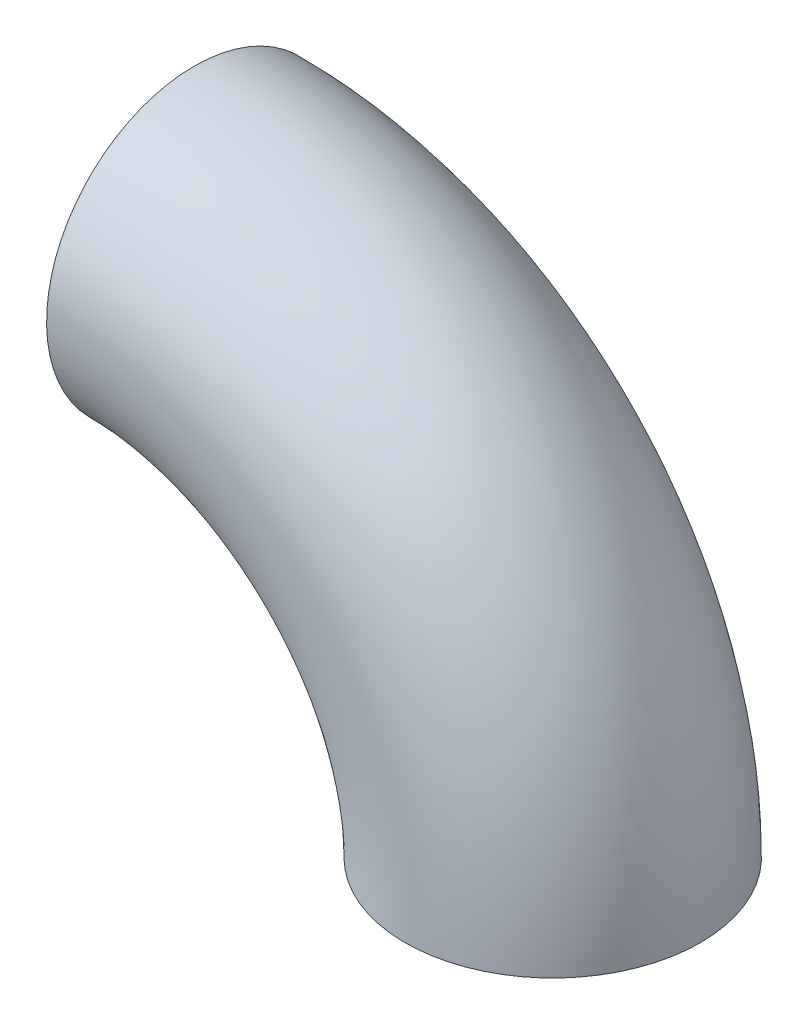
from build123d import *

# Parameters (mm, degrees)
SKETCH1_R   = 22.225
SKETCH1_R_2 = 20.574


with BuildPart() as part:
    # Sweep1: sweep along a curve in space
    with BuildLine() as sweep1_path:
        ThreePointArc((22.225, 0, 0), (-0.093463274, 53.881536726, 0), (-53.975, 76.2, 0))
    # Sketch1 → Sweep1 (sweep)
    with BuildSketch(Plane(origin=(0, 0, 0), x_dir=(1, 0, 0), z_dir=(0, 1, 0))):
        Circle(SKETCH1_R)
        Circle(SKETCH1_R_2, mode=Mode.SUBTRACT)
    sweep(path=sweep1_path.line)


solid = part.part
